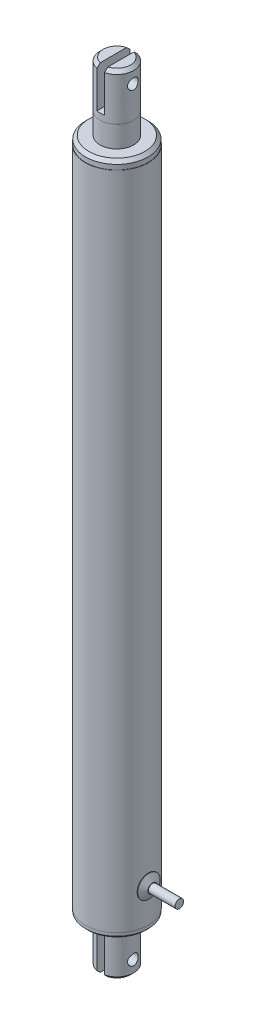
from build123d import *

# Parameters (mm, degrees)
SKETCH1_R           = 14.986
BOSS_EXTRUDE1_DEPTH = 313.944
SKETCH2_R           = 14.859
BOSS_EXTRUDE2_DEPTH = 2.54
CHAMFER1_SIZE       = 1.016
SKETCH3_R           = 8.001
BOSS_EXTRUDE3_DEPTH = 22.098
CHAMFER2_SIZE       = 1.524
SKETCH4_R           = 2.54
CUT_EXTRUDE1_DEPTH  = 21.59
SKETCH5_W           = 3.556
SKETCH5_H           = 22.881169146
CUT_EXTRUDE2_DEPTH  = 21.59
SKETCH6_R           = 5.334
BOSS_EXTRUDE4_DEPTH = 2.032
CHAMFER3_SIZE       = 1.778
CHAMFER3_SIZE2      = 3.079586336
SKETCH7_R           = 2.032
BOSS_EXTRUDE5_DEPTH = 12.7
SKETCH8_R           = 14.859
BOSS_EXTRUDE6_DEPTH = 3.81
CHAMFER4_SIZE       = 1.524
SKETCH9_R           = 8.001
BOSS_EXTRUDE7_DEPTH = 10.16
SKETCH10_R          = 8.001
BOSS_EXTRUDE8_DEPTH = 22
CHAMFER5_SIZE       = 1.524
SKETCH11_R          = 2.54
CUT_EXTRUDE3_DEPTH  = 21.844
SKETCH12_W          = 3.556
SKETCH12_H          = 19.05
CUT_EXTRUDE4_DEPTH  = 21.844


with BuildPart() as part:
    # Sketch1 → Boss-Extrude1 (new body)
    with BuildSketch(Plane(origin=(0, 0, 0), x_dir=(1, 0, 0), z_dir=(0, 1, 0))):
        with Locations(Location((0, 0, 0), (0, 0, 270))):  # turned: the seam where the file's is
            Circle(SKETCH1_R)
    extrude(amount=BOSS_EXTRUDE1_DEPTH)

    # Sketch2 → Boss-Extrude2 (add)
    with BuildSketch(Plane.XZ):
        with Locations(Location((0, 0, 0), (0, 0, 90))):  # turned: the seam where the file's is
            Circle(SKETCH2_R)
    extrude(amount=BOSS_EXTRUDE2_DEPTH)

    # Chamfer1
    chamfer1_edges = [part.edges().sort_by_distance(p)[0] for p in [
        (0, -2.54, -14.859),
    ]]
    chamfer(chamfer1_edges, length=CHAMFER1_SIZE)

    # Sketch3 → Boss-Extrude3 (add)
    with BuildSketch(Plane.XZ.offset(2.54)):
        with Locations(Location((0, 0, 0), (0, 0, 270))):  # turned: the seam where the file's is
            Circle(SKETCH3_R)
    extrude(amount=BOSS_EXTRUDE3_DEPTH)

    # Chamfer2
    chamfer2_edges = [part.edges().sort_by_distance(p)[0] for p in [
        (0, -24.638, 8.001),
    ]]
    chamfer(chamfer2_edges, length=CHAMFER2_SIZE)

    # Sketch4 → Cut-Extrude1 (cut)
    with BuildSketch(Plane.ZY.offset(8.001)):
        with Locations((0, -17.638)):
            Circle(SKETCH4_R)
    extrude(amount=-CUT_EXTRUDE1_DEPTH, mode=Mode.SUBTRACT)

    # Sketch5 → Cut-Extrude2 (cut)
    with BuildSketch(Plane(origin=(0, 0, -8.001), x_dir=(-1, 0, 0), z_dir=(0, 0, -1))):
        with Locations((-0.127, -17.536584573)):
            Rectangle(SKETCH5_W, SKETCH5_H)
    extrude(amount=-CUT_EXTRUDE2_DEPTH, mode=Mode.SUBTRACT)

    # Sketch8 → Boss-Extrude6 (add)
    with BuildSketch(Plane(origin=(0, 313.944, 0), x_dir=(1, 0, 0), z_dir=(0, 1, 0))):
        with Locations(Location((0, 0, 0), (0, 0, 270))):  # turned: the seam where the file's is
            Circle(SKETCH8_R)
    extrude(amount=BOSS_EXTRUDE6_DEPTH)

    # Chamfer4
    chamfer4_edges = [part.edges().sort_by_distance(p)[0] for p in [
        (0, 317.754, -14.859),
    ]]
    chamfer(chamfer4_edges, length=CHAMFER4_SIZE)

    # Sketch9 → Boss-Extrude7 (add)
    with BuildSketch(Plane(origin=(0, 317.754, 0), x_dir=(1, 0, 0), z_dir=(0, 1, 0))):
        with Locations(Location((0, 0, 0), (0, 0, 258.091508286))):  # turned: the seam where the file's is
            Circle(SKETCH9_R)
    extrude(amount=BOSS_EXTRUDE7_DEPTH)


with BuildPart() as body_2:
    # Sketch6 → Boss-Extrude4 (new body)
    with BuildSketch(Plane(origin=(14.986, 0, 0), x_dir=(0, 0, -1), z_dir=(1, 0, 0))):
        with Locations((0, 16.201300922)):
            Circle(SKETCH6_R)
    extrude(amount=BOSS_EXTRUDE4_DEPTH)

    # Chamfer3
    chamfer3_edges = [body_2.edges().sort_by_distance(p)[0] for p in [
        (17.018, 16.201300922, 5.334),
    ]]
    chamfer3_side = [body_2.faces().sort_by_distance(p)[0] for p in [
        (16.002, 16.201300922, 5.334),
    ]]
    chamfer(chamfer3_edges, length=CHAMFER3_SIZE, length2=CHAMFER3_SIZE2, reference=chamfer3_side[0])

    # Sketch7 → Boss-Extrude5 (add)
    with BuildSketch(Plane(origin=(17.018, 0, 0), x_dir=(0, 0, -1), z_dir=(1, 0, 0))):
        with Locations((0, 16.201300922)):
            Circle(SKETCH7_R)
    extrude(amount=BOSS_EXTRUDE5_DEPTH)


with BuildPart() as body_3:
    # Sketch10 → Boss-Extrude8 (new body)
    with BuildSketch(Plane(origin=(0, 327.914, 0), x_dir=(1, 0, 0), z_dir=(0, 1, 0))):
        with Locations(Location((0, 0, 0), (0, 0, 270))):  # turned: the seam where the file's is
            Circle(SKETCH10_R)
    extrude(amount=BOSS_EXTRUDE8_DEPTH)

    # Chamfer5
    chamfer5_edges = [body_3.edges().sort_by_distance(p)[0] for p in [
        (0, 349.914, -8.001),
    ]]
    chamfer(chamfer5_edges, length=CHAMFER5_SIZE)

    # Sketch11 → Cut-Extrude3 (cut)
    with BuildSketch(Plane.ZY.offset(8.001)):
        with Locations((0, 342.914)):
            Circle(SKETCH11_R)
    extrude(amount=-CUT_EXTRUDE3_DEPTH, mode=Mode.SUBTRACT)

    # Sketch12 → Cut-Extrude4 (cut)
    with BuildSketch(Plane(origin=(0, 0, -8.001), x_dir=(-1, 0, 0), z_dir=(0, 0, -1))):
        with Locations((-0.127, 340.389)):
            Rectangle(SKETCH12_W, SKETCH12_H)
    extrude(amount=-CUT_EXTRUDE4_DEPTH, mode=Mode.SUBTRACT)


solid = Compound([part.part, body_2.part, body_3.part])
